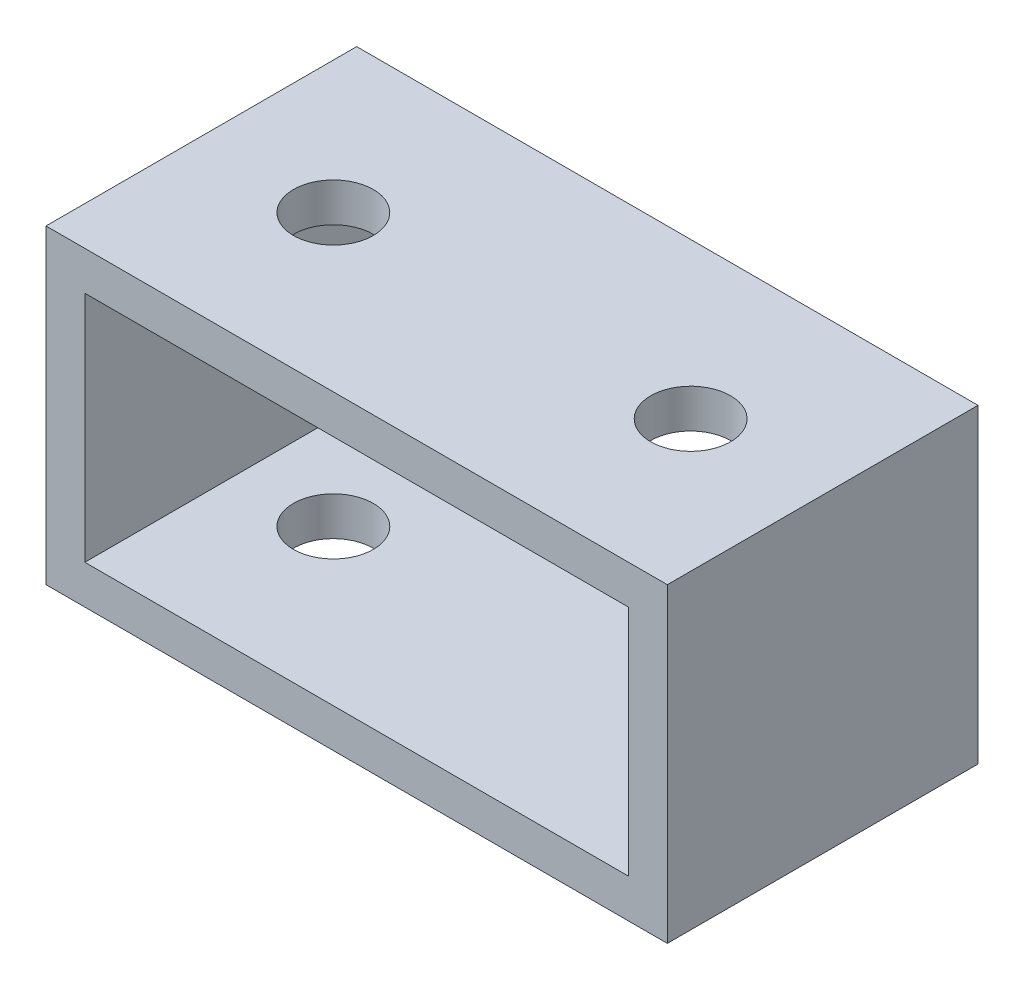
from build123d import *

# Parameters (mm, degrees)
SKETCH1_W               = 50.8
SKETCH1_H               = 25.4
SKETCH1_W_2             = 44.45
SKETCH1_H_2             = 19.05
BOSS_EXTRUDE1_DEPTH     = 25.4
SKETCH8_R               = 3.2639
CUT_EXTRUDE1_DEPTH      = 1
CUT_EXTRUDE1_DEPTH_BACK = 26.4


with BuildPart() as part:
    # Sketch1 → Boss-Extrude1 (new body)
    with BuildSketch(Plane.XY):
        with Locations((25.4, 12.7)):
            Rectangle(SKETCH1_W, SKETCH1_H)
        with Locations((25.4, 12.7)):
            Rectangle(SKETCH1_W_2, SKETCH1_H_2, mode=Mode.SUBTRACT)
    extrude(amount=BOSS_EXTRUDE1_DEPTH)

    # Sketch8 → Cut-Extrude1 (cut, two sides)
    with BuildSketch(Plane(origin=(0, 25.4, 0), x_dir=(1, 0, 0), z_dir=(0, 1, 0))) as cut_extrude1_sk:
        with Locations((10.795, -12.7)):
            Circle(SKETCH8_R)
        with Locations((40.005, -12.7)):
            Circle(SKETCH8_R)
    extrude(amount=CUT_EXTRUDE1_DEPTH, mode=Mode.SUBTRACT)
    extrude(cut_extrude1_sk.sketch, amount=-CUT_EXTRUDE1_DEPTH_BACK, mode=Mode.SUBTRACT)


solid = part.part
